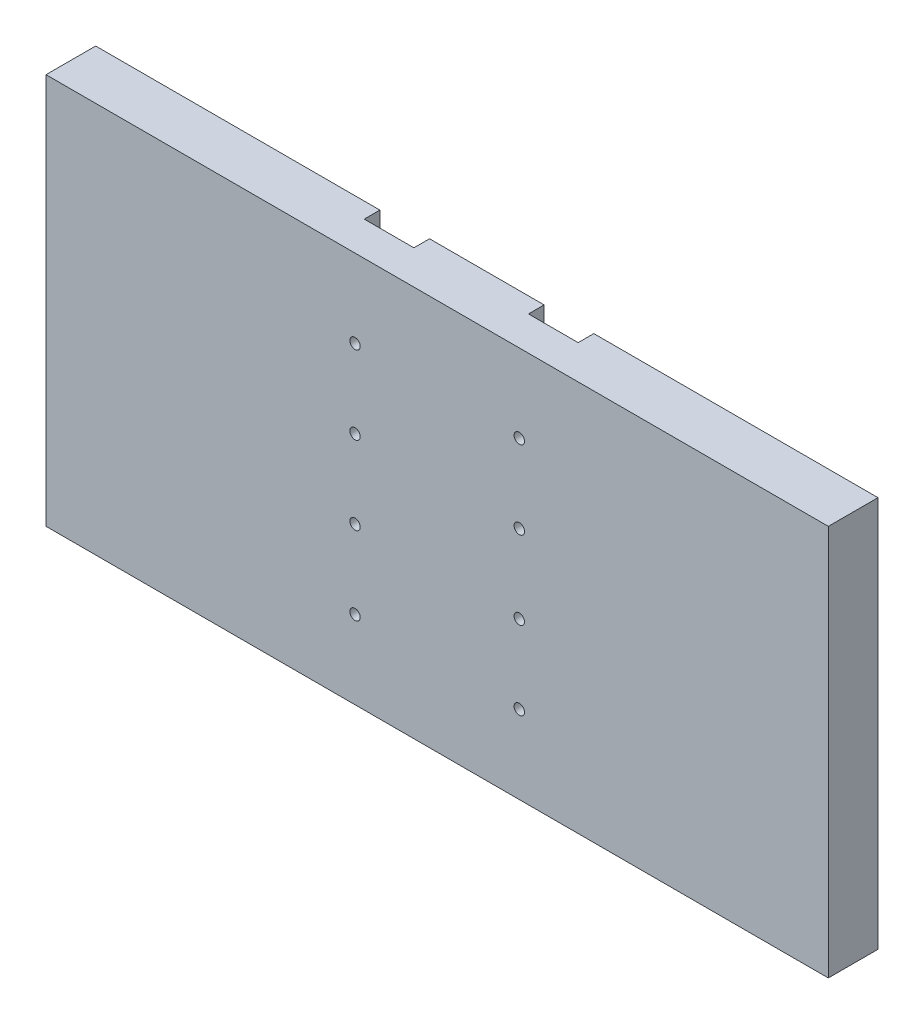
from build123d import *

# Parameters (mm, degrees)
SKETCH1_W           = 300
SKETCH1_H           = 150
BOSS_EXTRUDE1_DEPTH = 19.05
SKETCH1_3_W         = 19.05
SKETCH1_3_H         = 150
CUT_EXTRUDE1_DEPTH  = 6
SKETCH4_R           = 2
CUT_EXTRUDE3_DEPTH  = 336.663972598


with BuildPart() as part:
    # Sketch1 → Boss-Extrude1 (new body)
    with BuildSketch(Plane.XY):
        with Locations((150, 75)):
            Rectangle(SKETCH1_W, SKETCH1_H)
    extrude(amount=BOSS_EXTRUDE1_DEPTH)

    # Sketch1_3 → Cut-Extrude1 (cut)
    with BuildSketch(Plane.XY):
        with Locations((118.504, 75)):
            Rectangle(SKETCH1_3_W, SKETCH1_3_H)
        with Locations((181.496, 75)):
            Rectangle(SKETCH1_3_W, SKETCH1_3_H)
    extrude(amount=CUT_EXTRUDE1_DEPTH, mode=Mode.SUBTRACT)

    # Sketch4 → Cut-Extrude3 (cut, through all)
    with BuildSketch(Plane(origin=(0, 0, 6), x_dir=(-1, 0, 0), z_dir=(0, 0, -1))):
        with Locations((-118.504, 30)):
            Circle(SKETCH4_R)
        with Locations((-181.496, 30)):
            Circle(SKETCH4_R)
        with Locations((-181.496, 60)):
            Circle(SKETCH4_R)
        with Locations((-181.496, 90)):
            Circle(SKETCH4_R)
        with Locations((-181.496, 120)):
            Circle(SKETCH4_R)
        with Locations((-118.504, 60)):
            Circle(SKETCH4_R)
        with Locations((-118.504, 90)):
            Circle(SKETCH4_R)
        with Locations((-118.504, 120)):
            Circle(SKETCH4_R)
    extrude(amount=-CUT_EXTRUDE3_DEPTH, mode=Mode.SUBTRACT)


solid = part.part
